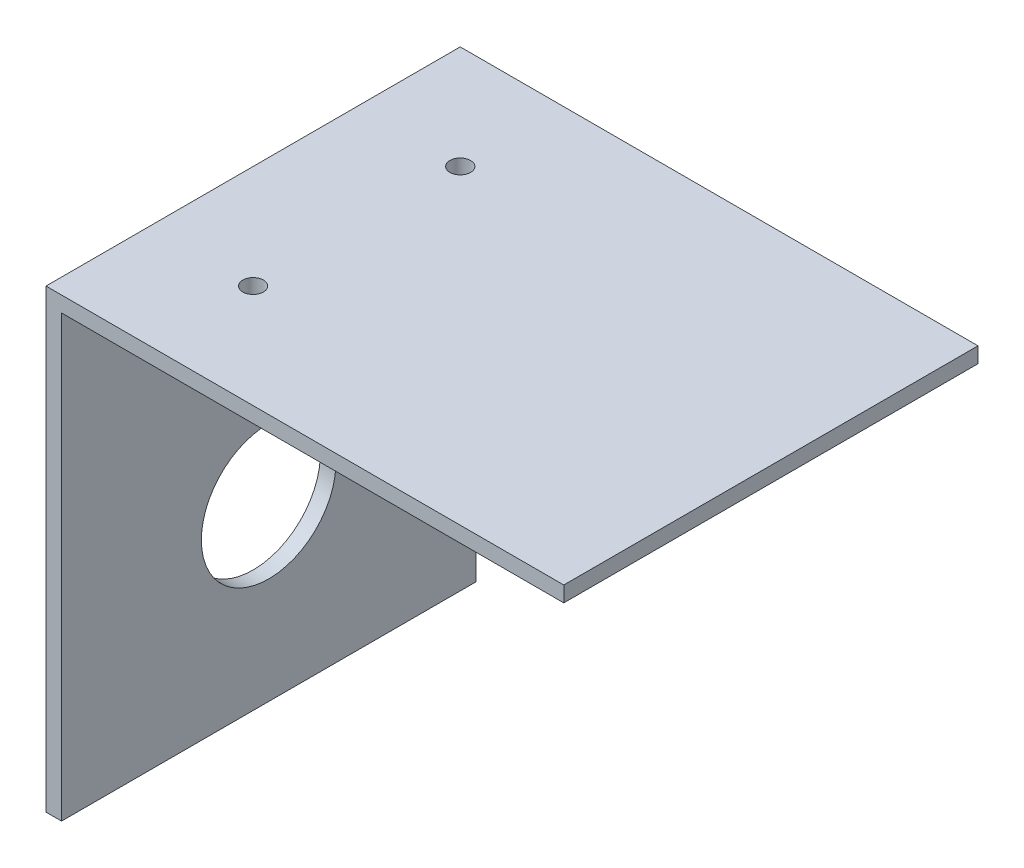
from build123d import *

# Parameters (mm, degrees)
SKETCH2_W           = 100
SKETCH2_H           = 80
BOSS_EXTRUDE1_DEPTH = 3
SKETCH3_W           = 3
SKETCH3_H           = 80
BOSS_EXTRUDE2_DEPTH = 100
SKETCH8_R           = 2
CUT_EXTRUDE3_DEPTH  = 61
SKETCH6_R           = 13
CUT_EXTRUDE4_DEPTH  = 10
SKETCH9_W           = 3
SKETCH9_H           = 80
CUT_EXTRUDE5_DEPTH  = 15


with BuildPart() as part:
    # Sketch2 → Boss-Extrude1 (new body)
    with BuildSketch(Plane(origin=(0, 0, 0), x_dir=(1, 0, 0), z_dir=(0, 1, 0))):
        Rectangle(SKETCH2_W, SKETCH2_H)
    extrude(amount=BOSS_EXTRUDE1_DEPTH)

    # Sketch3 → Boss-Extrude2 (add)
    with BuildSketch(Plane.XZ):
        with Locations((-48.5, 0)):
            Rectangle(SKETCH3_W, SKETCH3_H)
    extrude(amount=BOSS_EXTRUDE2_DEPTH)

    # Sketch8 → Cut-Extrude3 (cut)
    with BuildSketch(Plane(origin=(0, 3, 0), x_dir=(1, 0, 0), z_dir=(0, 1, 0))):
        with Locations((-30, 20)):
            Circle(SKETCH8_R)
        with Locations((-30, -20)):
            Circle(SKETCH8_R)
    extrude(amount=-CUT_EXTRUDE3_DEPTH, mode=Mode.SUBTRACT)

    # Sketch6 → Cut-Extrude4 (cut)
    with BuildSketch(Plane.ZY.offset(50)):
        with Locations((0, -51.5)):
            Circle(SKETCH6_R)
    extrude(amount=-CUT_EXTRUDE4_DEPTH, mode=Mode.SUBTRACT)

    # Sketch9 → Cut-Extrude5 (cut)
    with BuildSketch(Plane.XZ.offset(100)):
        with Locations((-48.5, 0)):
            Rectangle(SKETCH9_W, SKETCH9_H)
    extrude(amount=-CUT_EXTRUDE5_DEPTH, mode=Mode.SUBTRACT)


solid = part.part
